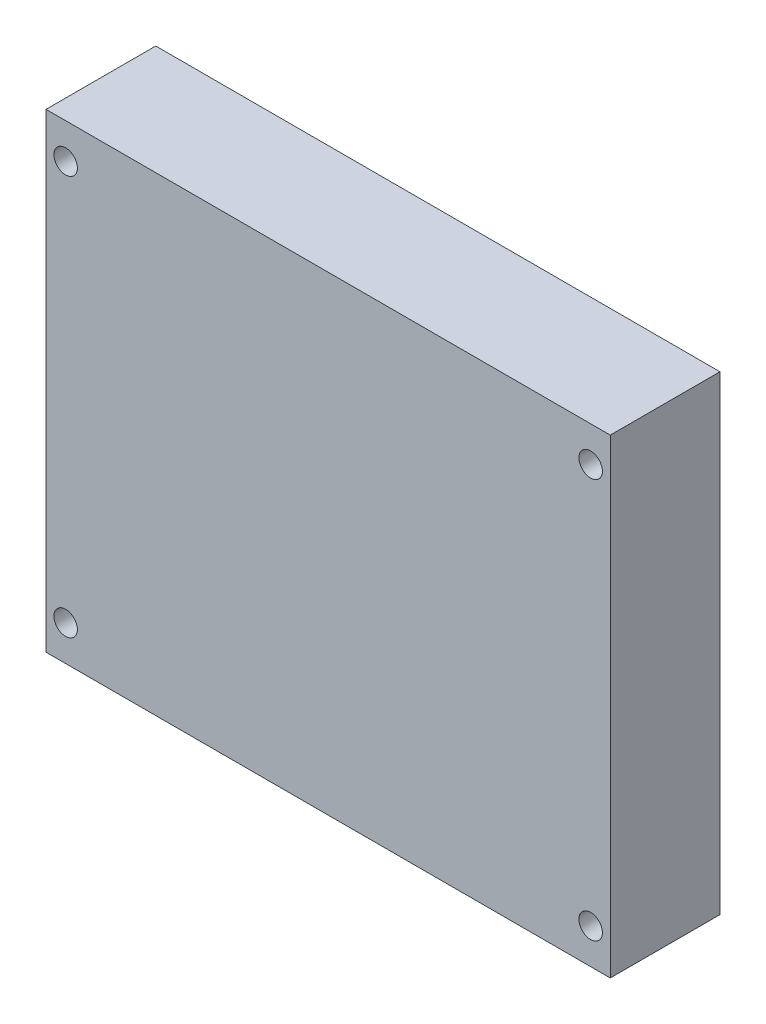
from build123d import *

# Parameters (mm, degrees)
CROQUIS1_W              = 72
CROQUIS1_H              = 60
CROQUIS1_R              = 1.5
SALIENTE_EXTRUIR1_DEPTH = 14


with BuildPart() as part:
    # Croquis1 → Saliente-Extruir1 (new body)
    with BuildSketch(Plane.XY):
        with Locations((36, 30)):
            Rectangle(CROQUIS1_W, CROQUIS1_H)
        with Locations((2.5, 55.5)):
            Circle(CROQUIS1_R, mode=Mode.SUBTRACT)
        with Locations((69.5, 55.5)):
            Circle(CROQUIS1_R, mode=Mode.SUBTRACT)
        with Locations((69.5, 4.5)):
            Circle(CROQUIS1_R, mode=Mode.SUBTRACT)
        with Locations((2.5, 4.5)):
            Circle(CROQUIS1_R, mode=Mode.SUBTRACT)
    extrude(amount=SALIENTE_EXTRUIR1_DEPTH)


solid = part.part
